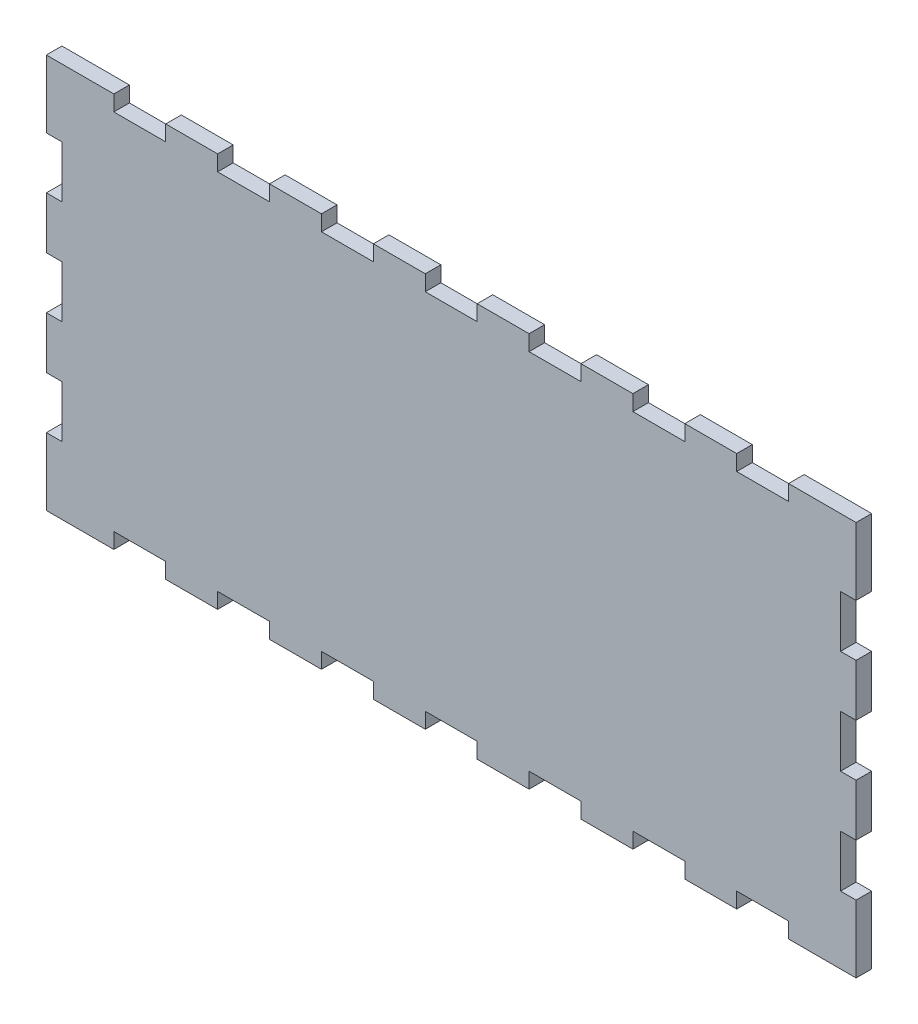
from build123d import *

# Parameters (mm, degrees)
BOSS_EXTRUDE1_DEPTH = 3


with BuildPart() as part:
    # Sketch1 → Boss-Extrude1 (new body)
    with BuildSketch(Plane.XY):
        Polygon((0, 60), (0, 50), (-3, 50), (-3, 40), (0, 40), (0, 30), (-3, 30), (-3, 20), (0, 20), (0, 10), (-3, 10), (-3, 0), (-3, -3), (0, -3), (10, -3), (10, 0), (20, 0), (20, -3), (30, -3), (30, 0), (40, 0), (40, -3), (50, -3), (50, 0), (60, 0), (60, -3), (70, -3), (70, 0), (80, 0), (80, -3), (90, -3), (90, 0), (100, 0), (100, -3), (110, -3), (110, 0), (120, 0), (120, -3), (130, -3), (130, 0), (140, 0), (140, -3), (150, -3), (153, -3), (153, 0), (153, 10), (150, 10), (150, 20), (153, 20), (153, 30), (150, 30), (150, 40), (153, 40), (153, 50), (150, 50), (150, 60), (153, 60), (153, 70), (153, 73), (150, 73), (140, 73), (140, 70), (130, 70), (130, 73), (120, 73), (120, 70), (110, 70), (110, 73), (100, 73), (100, 70), (90, 70), (90, 73), (80, 73), (80, 70), (70, 70), (70, 73), (60, 73), (60, 70), (50, 70), (50, 73), (40, 73), (40, 70), (30, 70), (30, 73), (20, 73), (20, 70), (10, 70), (10, 73), (0, 73), (-3, 73), (-3, 70), (-3, 60), align=None)
    extrude(amount=BOSS_EXTRUDE1_DEPTH)


solid = part.part
